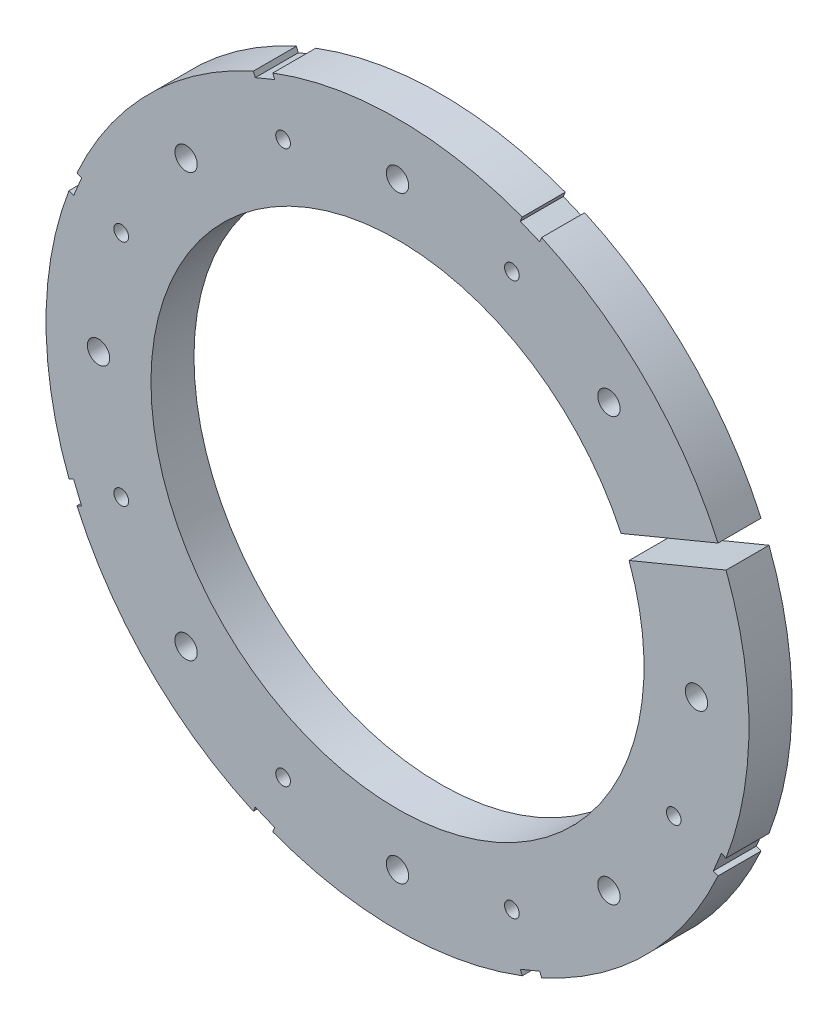
from build123d import *

# Parameters (mm, degrees)
SKETCH4_R                 = 42.545
BOSS_EXTRUDE2_DEPTH       = 5.207
SKETCH5_R                 = 29.845
CUT_EXTRUDE5_DEPTH        = 6.207
CUT_EXTRUDE11_DEPTH       = 6.207
F_6_32_TAPPED_HOLE1_D     = 2.7051
F_2_56_TAPPED_HOLE1_D     = 1.778
F_2_56_TAPPED_HOLE1_DEPTH = 3.302
F_2_56_TAPPED_HOLE1_TIP   = 0.53416509


with BuildPart() as part:
    # Sketch4 → Boss-Extrude2 (new body)
    with BuildSketch(Plane.XY):
        Circle(SKETCH4_R)
    extrude(amount=BOSS_EXTRUDE2_DEPTH)

    # Sketch5 → Cut-Extrude5 (cut, through all)
    with BuildSketch(Plane.XY.offset(5.207)):
        Circle(SKETCH5_R)
    extrude(amount=-CUT_EXTRUDE5_DEPTH, mode=Mode.SUBTRACT)

    # Sketch8 → Cut-Extrude11 (cut, through all)
    with BuildSketch(Plane.XY.offset(5.207)):
        Polygon((45.273745286, 20.127637411), (26.500513186, 12.351510066), (27.472529104, 10.004856053), (46.245761204, 17.780983399), align=None)
        Polygon((17.697597616, 39.407110255), (15.350943603, 40.379126173), (14.864935644, 39.205799167), (17.211589657, 38.233783248), align=None)
        Polygon((-15.350943603, 40.379126173), (-17.697597616, 39.407110255), (-17.211589657, 38.233783248), (-14.864935644, 39.205799167), align=None)
        Polygon((-39.407110255, 17.697597616), (-40.379126173, 15.350943603), (-39.205799167, 14.864935644), (-38.233783248, 17.211589657), align=None)
        Polygon((-40.379126173, -15.350943603), (-39.407110255, -17.697597616), (-38.233783248, -17.211589657), (-39.205799167, -14.864935644), align=None)
        Polygon((-17.697597616, -39.407110255), (-15.350943603, -40.379126173), (-14.864935644, -39.205799167), (-17.211589657, -38.233783248), align=None)
        Polygon((15.350943603, -40.379126173), (17.697597616, -39.407110255), (17.211589657, -38.233783248), (14.864935644, -39.205799167), align=None)
        Polygon((39.407110255, -17.697597616), (40.379126173, -15.350943603), (39.205799167, -14.864935644), (38.233783248, -17.211589657), align=None)
    extrude(amount=-CUT_EXTRUDE11_DEPTH, mode=Mode.SUBTRACT)

    # #6-32 Tapped Hole1 (through all)
    with Locations(Plane.XY.offset(5.207)):
        with Locations((36.195, 0), (25.593729945, -25.593729945), (0, -36.195), (-25.593729945, -25.593729945), (-36.195, 0), (-25.593729945, 25.593729945), (0, 36.195), (25.593729945, 25.593729945)):
            Hole(F_6_32_TAPPED_HOLE1_D / 2)

    # #2-56 Tapped Hole1
    with Locations(Plane.XY.offset(5.207)):
        with Locations((13.851226834, 33.439819679), (-13.851226834, 33.439819679), (-33.439819679, 13.851226834), (-33.439819679, -13.851226834), (-13.851226834, -33.439819679), (13.851226834, -33.439819679), (33.439819679, -13.851226834), (33.439819679, 13.851226834)):
            Hole(F_2_56_TAPPED_HOLE1_D / 2, depth=F_2_56_TAPPED_HOLE1_DEPTH)
            with Locations((0, 0, -(F_2_56_TAPPED_HOLE1_DEPTH + F_2_56_TAPPED_HOLE1_TIP / 2))):  # 118° drill point
                Cone(0, F_2_56_TAPPED_HOLE1_D / 2, F_2_56_TAPPED_HOLE1_TIP, mode=Mode.SUBTRACT)


solid = part.part
